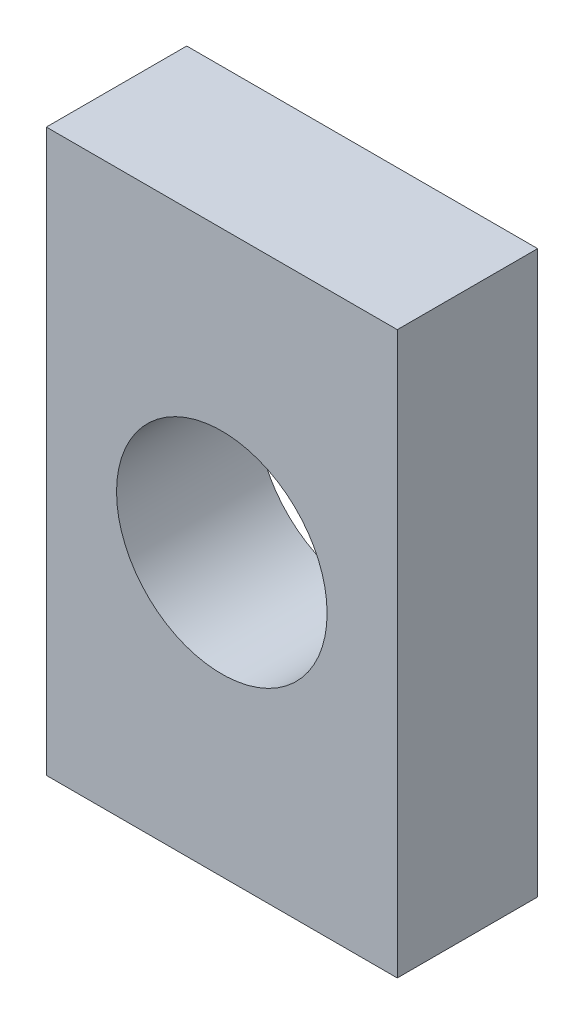
from build123d import *

# Parameters (mm, degrees)
ESBO_O1_W                = 5
ESBO_O1_H                = 8
ESBO_O1_R                = 1.5
RESSALTO_EXTRUS_O1_DEPTH = 2


with BuildPart() as part:
    # Esboço1 → Ressalto-extrusão1 (new body)
    with BuildSketch(Plane.XY):
        Rectangle(ESBO_O1_W, ESBO_O1_H)
        Circle(ESBO_O1_R, mode=Mode.SUBTRACT)
    extrude(amount=RESSALTO_EXTRUS_O1_DEPTH)


solid = part.part
